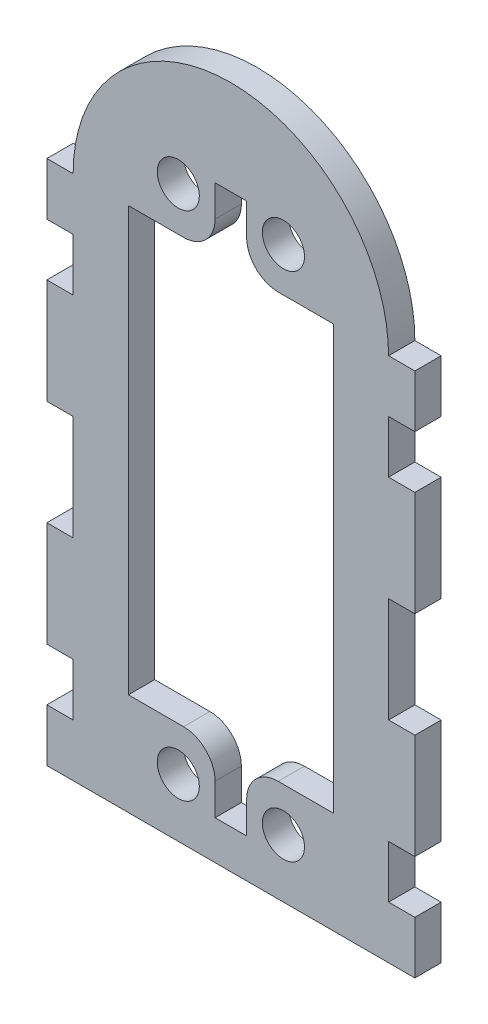
from build123d import *

# Parameters (mm, degrees)
CROQUIS1_R              = 2
SALIENTE_EXTRUIR1_DEPTH = 2.5
REDONDEO6_R             = 3
REDONDEO7_R             = 3
REDONDEO8_R             = 3


with BuildPart() as part:
    # Croquis1 → Saliente-Extruir1 (new body)
    with BuildSketch(Plane.XY):
        with BuildLine():
            Line((-15, 20.15), (-17.5, 20.15))
            Line((-17.5, 20.15), (-17.5, 15.15))
            Line((-17.5, 15.15), (-15, 15.15))
            Line((-15, 15.15), (-15, 10.15))
            Line((-15, 10.15), (-17.5, 10.15))
            Line((-17.5, 10.15), (-17.5, 0.15))
            Line((-17.5, 0.15), (-15, 0.15))
            Line((-15, 0.15), (-15, -9.85))
            Line((-15, -9.85), (-17.5, -9.85))
            Line((-17.5, -9.85), (-17.5, -19.85))
            Line((-17.5, -19.85), (-15, -19.85))
            Line((-15, -19.85), (-15, -24.85))
            Line((-15, -24.85), (-17.5, -24.85))
            Line((-17.5, -24.85), (-17.5, -29.85))
            Line((-17.5, -29.85), (-15, -29.85))
            Line((-15, -29.85), (15, -29.85))
            Line((15, -29.85), (17.5, -29.85))
            Line((17.5, -29.85), (17.5, -24.85))
            Line((17.5, -24.85), (15, -24.85))
            Line((15, -24.85), (15, -19.85))
            Line((15, -19.85), (17.5, -19.85))
            Line((17.5, -19.85), (17.5, -9.85))
            Line((17.5, -9.85), (15, -9.85))
            Line((15, -9.85), (15, 0.15))
            Line((15, 0.15), (17.5, 0.15))
            Line((17.5, 0.15), (17.5, 10.15))
            Line((17.5, 10.15), (15, 10.15))
            Line((15, 10.15), (15, 15.15))
            Line((15, 15.15), (17.5, 15.15))
            Line((17.5, 15.15), (17.5, 20.15))
            Line((17.5, 20.15), (15, 20.15))
            ThreePointArc((15, 20.15), (0, 35.15), (-15, 20.15))
        make_face()
        with Locations((-5, 24.315)):
            Circle(CROQUIS1_R, mode=Mode.SUBTRACT)
        with Locations((5, 24.315)):
            Circle(CROQUIS1_R, mode=Mode.SUBTRACT)
        with Locations((-5, -24.315)):
            Circle(CROQUIS1_R, mode=Mode.SUBTRACT)
        with Locations((5, -24.315)):
            Circle(CROQUIS1_R, mode=Mode.SUBTRACT)
        Polygon((-9.75, 20.15), (-1.5, 20.15), (-1.5, 26.15), (1.5, 26.15), (1.5, 20.15), (9.75, 20.15), (9.75, -20.15), (1.5, -20.15), (1.5, -26.15), (-1.5, -26.15), (-1.5, -20.15), (-9.75, -20.15), align=None, mode=Mode.SUBTRACT)
    extrude(amount=SALIENTE_EXTRUIR1_DEPTH)

    # Redondeo6
    redondeo6_edges = [part.edges().sort_by_distance(p)[0] for p in [
        (-1.5, -20.15, 1.25),
    ]]
    fillet(redondeo6_edges, radius=REDONDEO6_R)

    # Redondeo7
    redondeo7_edges = [part.edges().sort_by_distance(p)[0] for p in [
        (1.5, -20.15, 1.25),
    ]]
    fillet(redondeo7_edges, radius=REDONDEO7_R)

    # Redondeo8
    redondeo8_edges = [part.edges().sort_by_distance(p)[0] for p in [
        (1.5, 20.15, 1.25),
        (-1.5, 20.15, 1.25),
    ]]
    fillet(redondeo8_edges, radius=REDONDEO8_R)


solid = part.part
